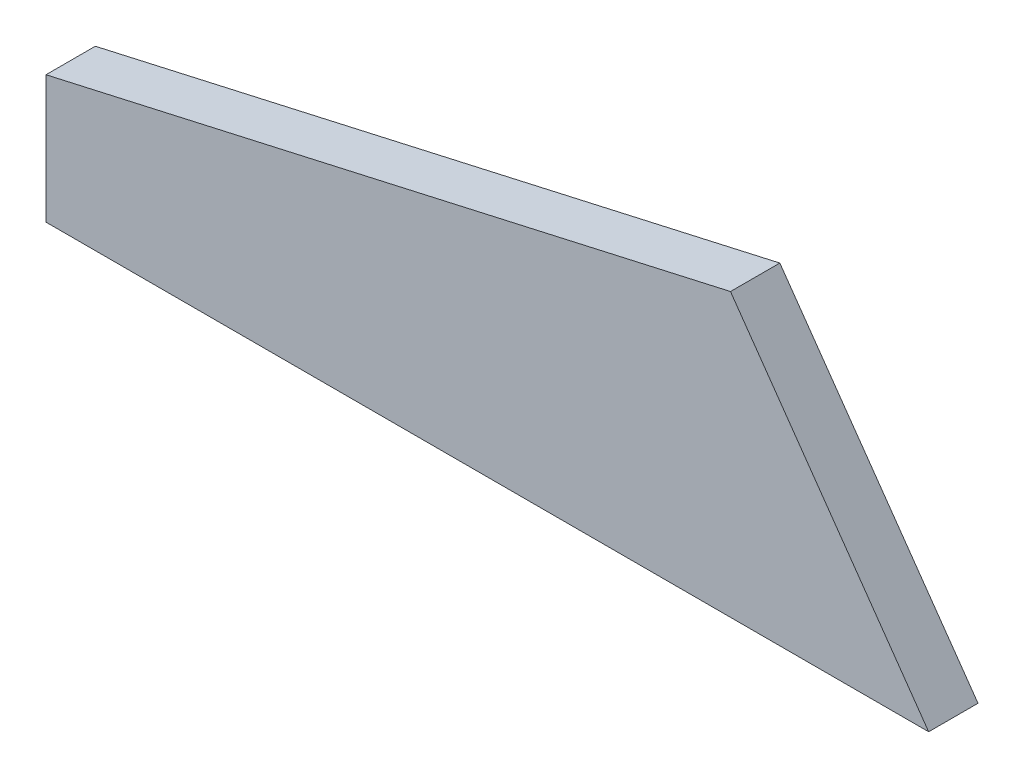
from build123d import *

# Parameters (mm, degrees)
BOSS_EXTRU_1_DEPTH = 8.5


with BuildPart() as part:
    # Esquisse1 → Boss.-Extru.1 (new body)
    with BuildSketch(Plane.XY):
        Polygon((-115, 81.060173911), (-115, 103.060173911), (2.921545515, 129.674473857), (37.061989287, 81.060173911), align=None)
    extrude(amount=BOSS_EXTRU_1_DEPTH)


solid = part.part
